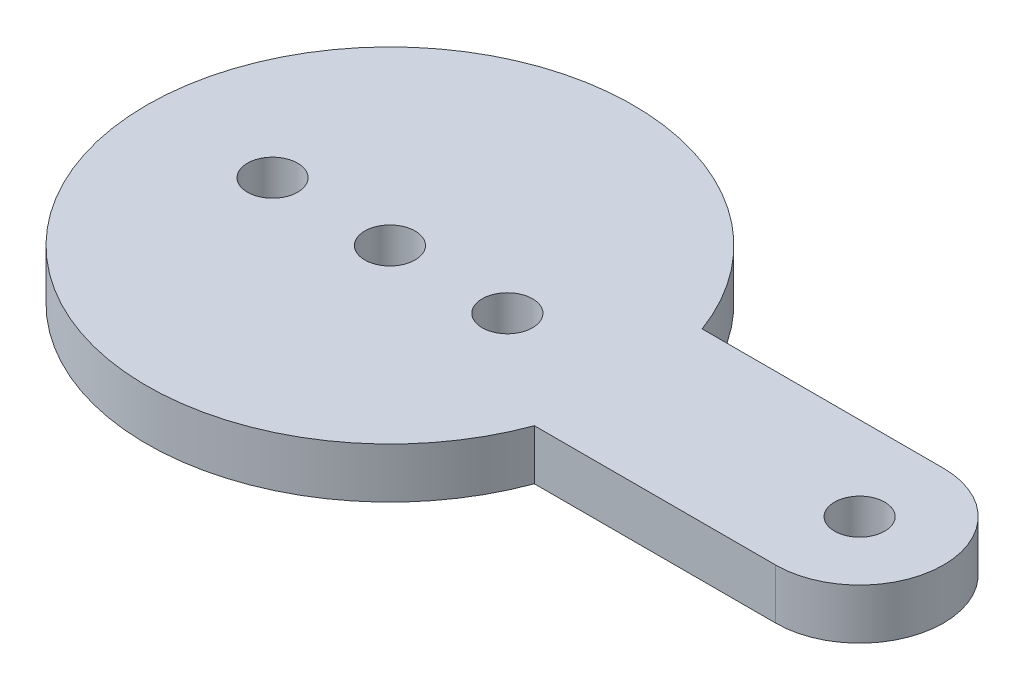
from build123d import *

# Parameters (mm, degrees)
SKETCH1_R           = 1.5
BOSS_EXTRUDE1_DEPTH = 3


with BuildPart() as part:
    # Sketch1 → Boss-Extrude1 (new body)
    with BuildSketch(Plane(origin=(0, 0, 0), x_dir=(1, 0, 0), z_dir=(0, 1, 0))):
        with BuildLine():
            Line((28, 5), (13.610657589, 5))
            ThreePointArc((13.610657589, 5), (-14.5, 0), (13.610657589, -5))
            Line((13.610657589, -5), (28, -5))
            ThreePointArc((28, -5), (33, 0), (28, 5))
        make_face()
        with Locations((28, 0)):
            Circle(SKETCH1_R, mode=Mode.SUBTRACT)
        Circle(SKETCH1_R, mode=Mode.SUBTRACT)
        with Locations((7, 0)):
            Circle(SKETCH1_R, mode=Mode.SUBTRACT)
        with Locations((-7, 0)):
            Circle(SKETCH1_R, mode=Mode.SUBTRACT)
    extrude(amount=BOSS_EXTRUDE1_DEPTH)


solid = part.part
